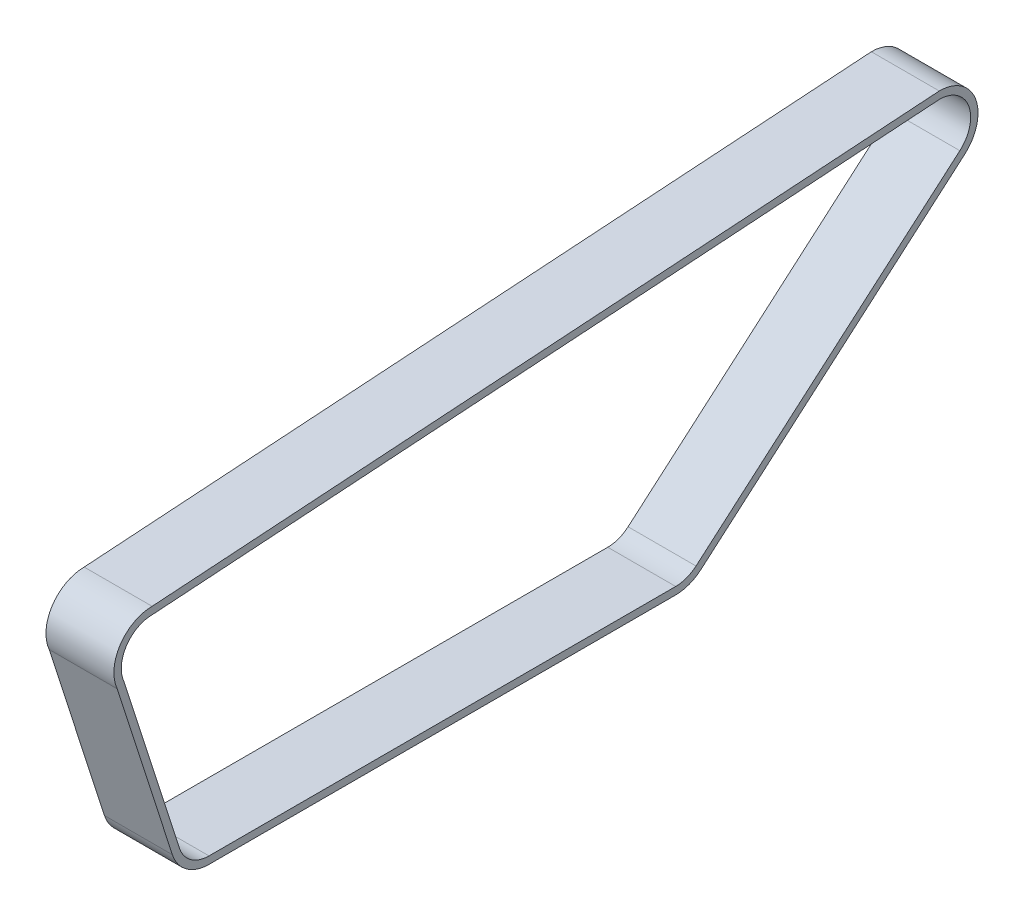
from build123d import *

# Parameters (mm, degrees)
EXTRUDE_1_DEPTH = 41.5


with BuildPart() as part:
    # 草图1 → 凸台-拉伸1 (new body)
    with BuildSketch(Plane.ZY):
        with BuildLine():
            Line((-247.135706549, 691.329742198), (233.685421601, 659.136990159))
            ThreePointArc((233.685421601, 659.136990159), (253.25995653, 648.399148569), (255.023393056, 626.142600064))
            Line((255.023393056, 626.142600064), (221.292164335, 521.502399447))
            ThreePointArc((221.292164335, 521.502399447), (212.760551455, 509.716531999), (198.925533748, 505.212381151))
            Line((198.925533748, 505.212381151), (-86.132619056, 505.212381151))
            ThreePointArc((-86.132619056, 505.212381151), (-94.324335579, 506.686356081), (-101.488444886, 510.923378563))
            Line((-101.488444886, 510.923378563), (-262.649988816, 650.041273838))
            ThreePointArc((-262.649988816, 650.041273838), (-269.292445055, 676.096205655), (-247.135706549, 691.329742198))
        make_face()
        with BuildLine():
            Line((-259.709511529, 653.447678589), (-98.547967599, 514.329783314))
            ThreePointArc((-98.547967599, 514.329783314), (-92.75570901, 510.904105562), (-86.132619056, 509.712381151))
            Line((-86.132619056, 509.712381151), (198.925533748, 509.712381151))
            ThreePointArc((198.925533748, 509.712381151), (210.111292745, 513.354035028), (217.00919252, 522.883034241))
            Line((217.00919252, 522.883034241), (250.816171993, 627.758227005))
            ThreePointArc((250.816171993, 627.758227005), (249.506743796, 645.91598122), (233.526965164, 654.637524387))
            Line((233.526965164, 654.637524387), (-247.294162986, 686.830276426))
            ThreePointArc((-247.294162986, 686.830276426), (-265.102438575, 674.453366381), (-259.709511529, 653.447678589))
        make_face(mode=Mode.SUBTRACT)
    extrude(amount=EXTRUDE_1_DEPTH)


solid = part.part
